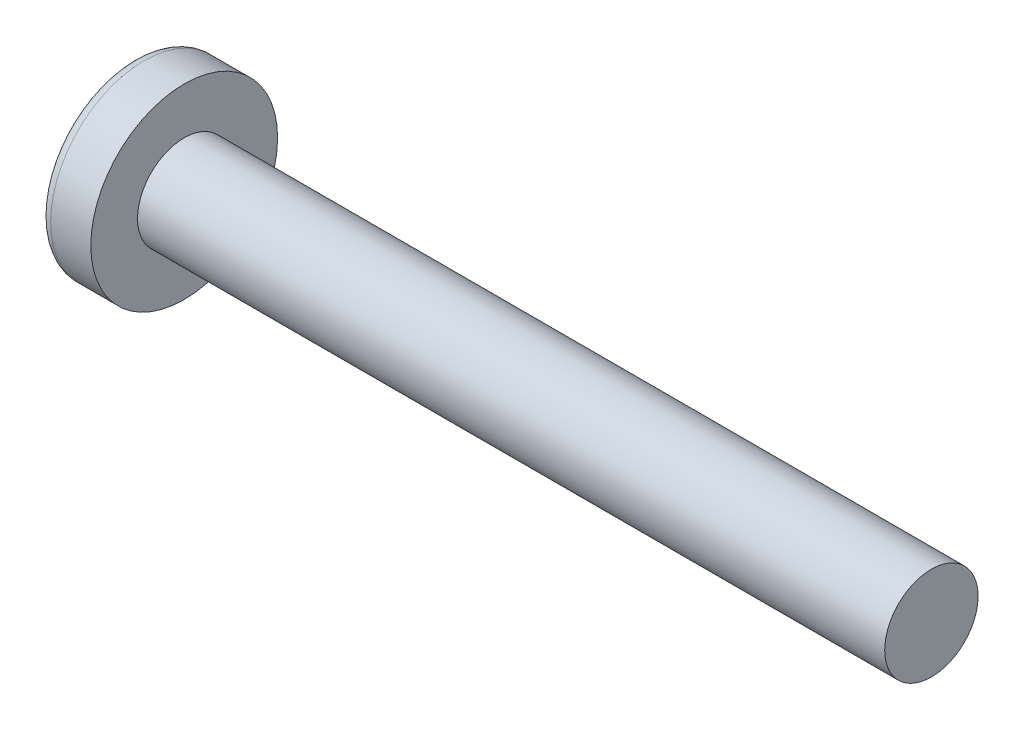
from build123d import *

# Parameters (mm, degrees)
SKETCH3_W         = 0.7
SKETCH3_H         = 2.68
SKETCH4_W         = 0.35
SKETCH4_H         = 0.35
CIRPATTERN1_COUNT = 2
CIRPATTERN1_ANGLE = 90


with BuildPart() as part:
    # BodySke → Base-Revolve (revolve)
    with BuildSketch(Plane.XY):
        with BuildLine():
            Line((2.1, 1.25), (2.1, 2.5))
            Line((2.1, 2.5), (1.025105044, 2.5))
            ThreePointArc((1.025105044, 2.5), (0.890037493, 2.467874517), (0.783897345, 2.378378378))
            ThreePointArc((0.783897345, 2.378378378), (0.201025755, 1.252116085), (0, 0))
            Line((0, 0), (22.1, 0))
            Line((22.1, 0), (22.1, 1.25))
            Line((22.1, 1.25), (2.1, 1.25))
        make_face()
    revolve(axis=Axis((-25.4, 0, 0), (1, 0, 0)))

    # Sketch3 → Cut-Loft1 section 0
    with BuildSketch(Plane(origin=(0, 0, 0), x_dir=(0, 0, -1), z_dir=(1, 0, 0))):
        Rectangle(SKETCH3_W, SKETCH3_H)
    # Sketch4 → Cut-Loft1 section 1
    with BuildSketch(Plane(origin=(1.53, 0, 0), x_dir=(0, 0, -1), z_dir=(1, 0, 0))):
        Rectangle(SKETCH4_W, SKETCH4_H)
    cut_loft1 = loft(mode=Mode.SUBTRACT)

    # CirPattern1: Cut-Loft1 ×2 about axis
    cirpattern1_axis = Axis((0, 0, 0), (1, 0, 0))
    for i in range(1, CIRPATTERN1_COUNT):
        add(cut_loft1.rotate(cirpattern1_axis, i * CIRPATTERN1_ANGLE / (CIRPATTERN1_COUNT - 1)), mode=Mode.SUBTRACT)


solid = part.part
